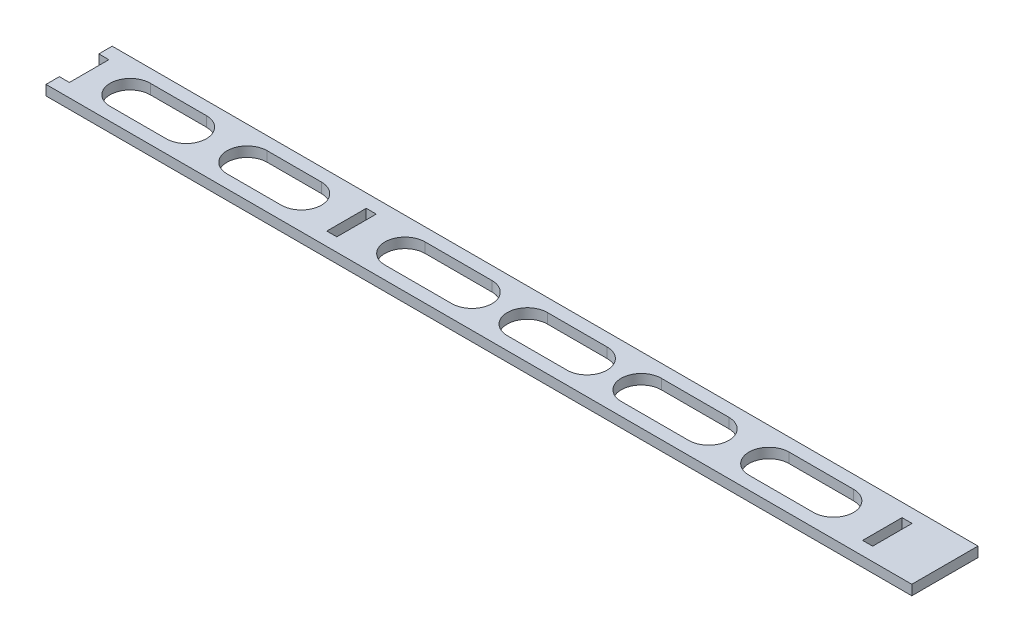
from build123d import *

# Parameters (mm, degrees)
SKETCH1_W           = 259
SKETCH1_H           = 19.8
BOSS_EXTRUDE1_DEPTH = 3
SKETCH2_W           = 3
SKETCH2_H           = 11.8
CUT_EXTRUDE1_DEPTH  = 3
CUT_EXTRUDE2_DEPTH  = 3


with BuildPart() as part:
    # Sketch1 → Boss-Extrude1 (new body)
    with BuildSketch(Plane(origin=(0, 0, 0), x_dir=(1, 0, 0), z_dir=(0, 1, 0))):
        with Locations((129.5, 9.9)):
            Rectangle(SKETCH1_W, SKETCH1_H)
    extrude(amount=BOSS_EXTRUDE1_DEPTH)

    # Sketch2 → Cut-Extrude1 (cut)
    with BuildSketch(Plane(origin=(0, 3, 0), x_dir=(1, 0, 0), z_dir=(0, 1, 0))):
        with Locations((1.5, 9.9)):
            Rectangle(SKETCH2_W, SKETCH2_H)
        with Locations((81.5, 9.9)):
            Rectangle(SKETCH2_W, SKETCH2_H)
        with Locations((241.78, 9.9)):
            Rectangle(SKETCH2_W, SKETCH2_H)
    extrude(amount=-CUT_EXTRUDE1_DEPTH, mode=Mode.SUBTRACT)

    # Sketch3 → Cut-Extrude2 (cut)
    with BuildSketch(Plane(origin=(0, 3, 0), x_dir=(1, 0, 0), z_dir=(0, 1, 0))):
        with BuildLine():
            Line((15.291475512, 15.9), (32.057683526, 15.9))
            ThreePointArc((32.057683526, 15.9), (38.057683526, 9.9), (32.057683526, 3.9))
            Line((32.057683526, 3.9), (15.291475512, 3.9))
            ThreePointArc((15.291475512, 3.9), (9.291475512, 9.9), (15.291475512, 15.9))
        make_face()
        with BuildLine():
            Line((97.499979326, 15.9), (117.51125986, 15.9))
            ThreePointArc((117.51125986, 15.9), (123.51125986, 9.9), (117.51125986, 3.9))
            Line((117.51125986, 3.9), (97.499979326, 3.9))
            ThreePointArc((97.499979326, 3.9), (91.499979326, 9.9), (97.499979326, 15.9))
        make_face()
        with BuildLine():
            Line((134.097186069, 15.9), (151.945084923, 15.9))
            ThreePointArc((151.945084923, 15.9), (157.945084923, 9.9), (151.945084923, 3.9))
            Line((151.945084923, 3.9), (134.097186069, 3.9))
            ThreePointArc((134.097186069, 3.9), (128.097186069, 9.9), (134.097186069, 15.9))
        make_face()
        with BuildLine():
            Line((50.266145994, 15.9), (66.491508589, 15.9))
            ThreePointArc((66.491508589, 15.9), (72.491508589, 9.9), (66.491508589, 3.9))
            Line((66.491508589, 3.9), (50.266145994, 3.9))
            ThreePointArc((50.266145994, 3.9), (44.266145994, 9.9), (50.266145994, 15.9))
        make_face()
        with BuildLine():
            Line((168.170447518, 15.9), (188.362009859, 15.9))
            ThreePointArc((188.362009859, 15.9), (194.362009859, 9.9), (188.362009859, 3.9))
            Line((188.362009859, 3.9), (168.170447518, 3.9))
            ThreePointArc((168.170447518, 3.9), (162.170447518, 9.9), (168.170447518, 15.9))
        make_face()
        with BuildLine():
            Line((206.39019052, 15.9), (225.680343827, 15.9))
            ThreePointArc((225.680343827, 15.9), (231.680343827, 9.9), (225.680343827, 3.9))
            Line((225.680343827, 3.9), (206.39019052, 3.9))
            ThreePointArc((206.39019052, 3.9), (200.39019052, 9.9), (206.39019052, 15.9))
        make_face()
    extrude(amount=-CUT_EXTRUDE2_DEPTH, mode=Mode.SUBTRACT)


solid = part.part
